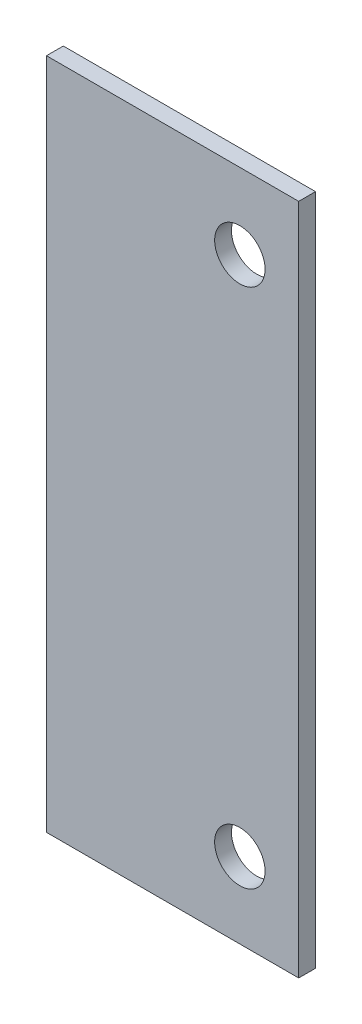
from build123d import *

# Parameters (mm, degrees)
SKETCH1_W           = 30
SKETCH1_H           = 80
BOSS_EXTRUDE1_DEPTH = 2
SKETCH2_R           = 3
CUT_EXTRUDE1_DEPTH  = 10


with BuildPart() as part:
    # Sketch1 → Boss-Extrude1 (new body)
    with BuildSketch(Plane.XY):
        with Locations((5, 0)):
            Rectangle(SKETCH1_W, SKETCH1_H)
    extrude(amount=BOSS_EXTRUDE1_DEPTH)

    # Sketch2 → Cut-Extrude1 (cut)
    with BuildSketch(Plane.XY.offset(2)):
        with Locations((13, 31)):
            Circle(SKETCH2_R)
        with Locations((13, -31)):
            Circle(SKETCH2_R)
    extrude(amount=-CUT_EXTRUDE1_DEPTH, mode=Mode.SUBTRACT)


solid = part.part
